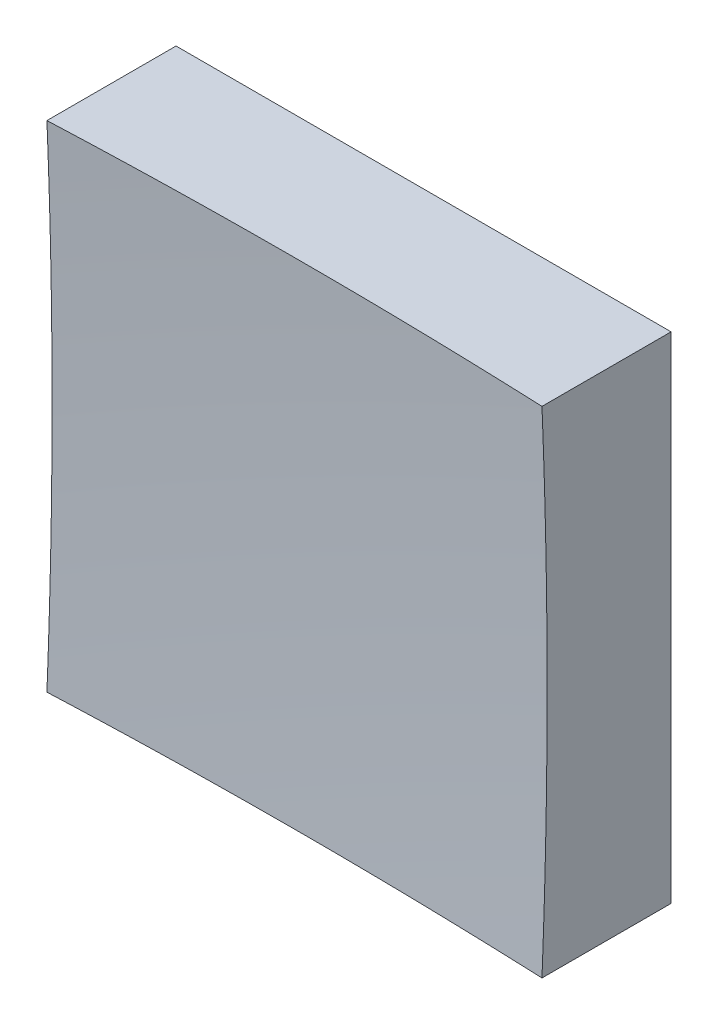
from build123d import *

# Parameters (mm, degrees)
SKETCH_1_W      = 12.5
SKETCH_1_H      = 12.5
EXTRUDE_1_DEPTH = 10


with BuildPart() as part:
    # 草图1 → 凸台-拉伸1 (new body)
    with BuildSketch(Plane.XY):
        Rectangle(SKETCH_1_W, SKETCH_1_H)
    extrude(amount=EXTRUDE_1_DEPTH)

    # 草图2 → 切除-旋转2 (revolve, cut)
    with BuildSketch(Plane(origin=(0, 0, 0), x_dir=(1, 0, 0), z_dir=(0, 1, 0))):
        with BuildLine():
            Line((146.226819272, -119.567720305), (0, -119.567720305))
            Line((0, -119.567720305), (0, -3))
            ThreePointArc((0, -3), (93.501759464, -35.70796712), (146.226819272, -119.567720305))
        make_face()
    revolve(axis=Axis((0, 0, 119.567720305), (0, 0, -1)), mode=Mode.SUBTRACT)


solid = part.part
